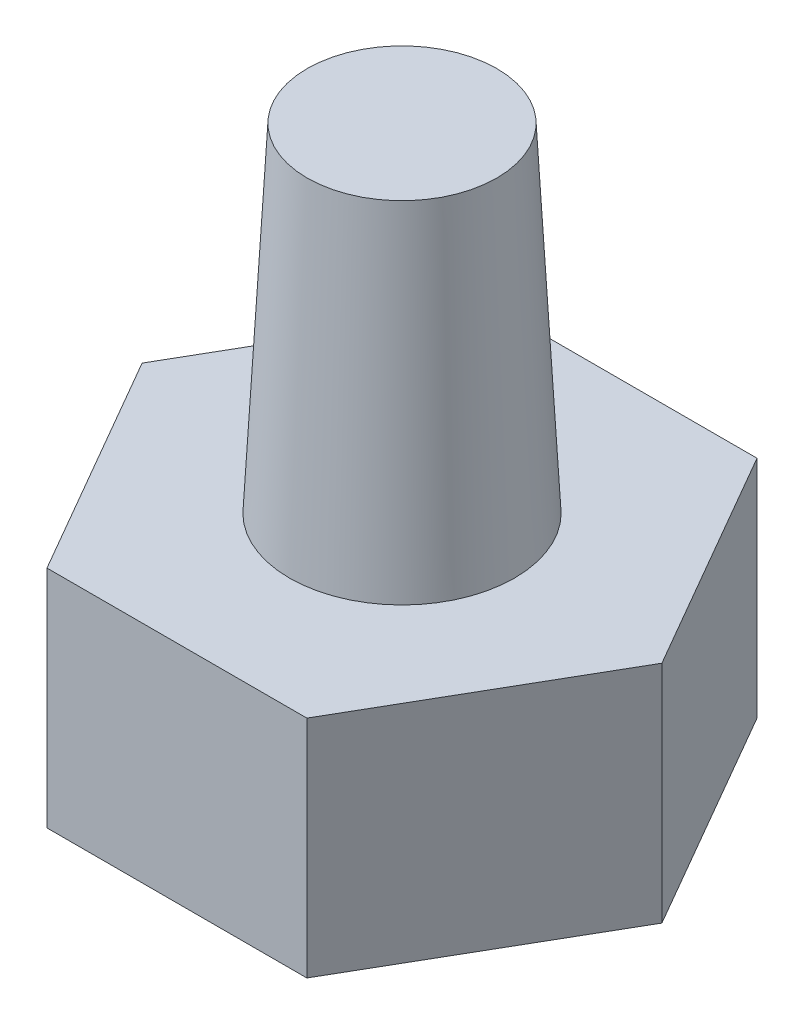
from build123d import *

# Parameters (mm, degrees)
BOSS_EXTRUDE1_DEPTH = 12
BOSS_EXTRUDE2_START = 12
SKETCH2_R           = 6
BOSS_EXTRUDE2_DEPTH = 18
BOSS_EXTRUDE2_TAPER = 3
SKETCH3_R           = 10
CUT_EXTRUDE1_DEPTH  = 10


with BuildPart() as part:
    # Sketch1 → Boss-Extrude1 (new body)
    with BuildSketch(Plane(origin=(0, 0, 0), x_dir=(1, 0, 0), z_dir=(0, 1, 0))):
        Polygon((13.856406461, 0), (6.92820323, 12), (-6.92820323, 12), (-13.856406461, 0), (-6.92820323, -12), (6.92820323, -12), align=None)
    extrude(amount=BOSS_EXTRUDE1_DEPTH)

    # Sketch2 → Boss-Extrude2 (add)
    with BuildSketch(Plane(origin=(0, 0, 0), x_dir=(1, 0, 0), z_dir=(0, 1, 0)).offset(BOSS_EXTRUDE2_START)):
        Circle(SKETCH2_R)
    extrude(amount=BOSS_EXTRUDE2_DEPTH, taper=BOSS_EXTRUDE2_TAPER)

    # Sketch3 → Cut-Extrude1 (cut)
    with BuildSketch(Plane(origin=(0, 0, 0), x_dir=(1, 0, 0), z_dir=(0, 1, 0))):
        Circle(SKETCH3_R)
    extrude(amount=CUT_EXTRUDE1_DEPTH, mode=Mode.SUBTRACT)


solid = part.part
